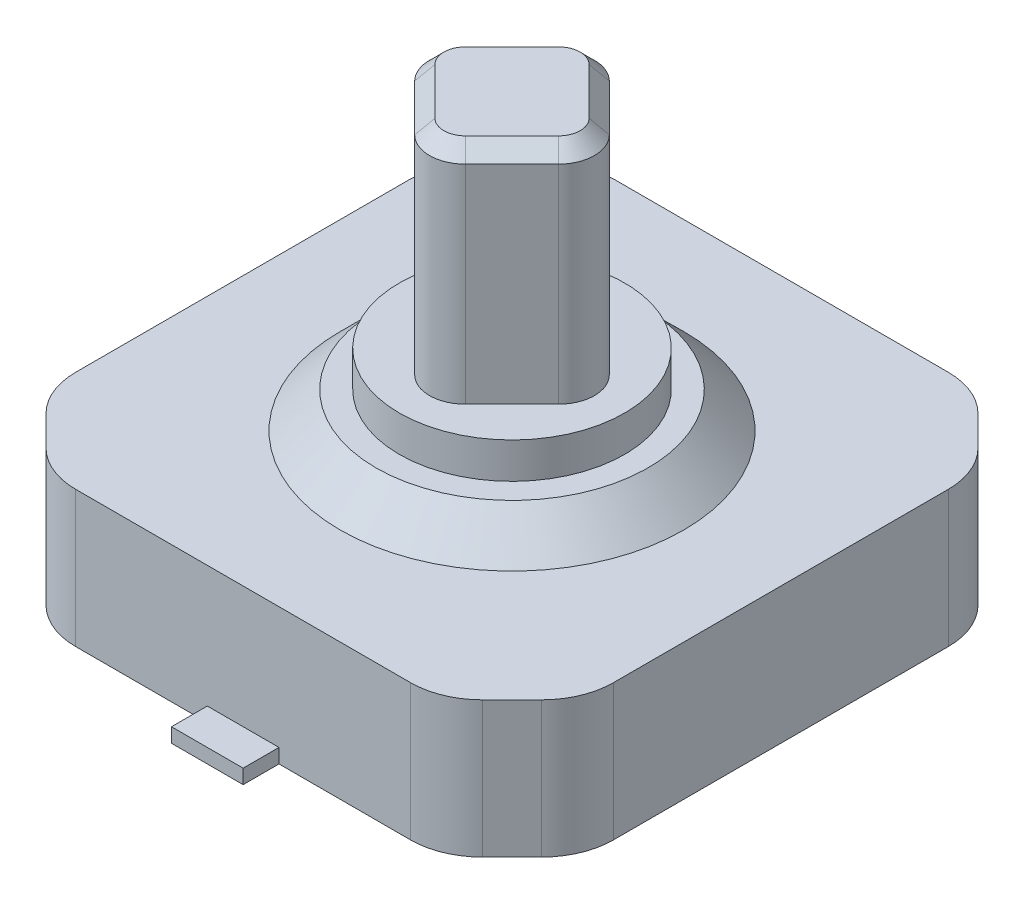
from build123d import *

# Parameters (mm, degrees)
BOSS_EXTRUDE1_DEPTH = 1.9
BOSS_EXTRUDE2_DEPTH = 6
SKETCH3_R           = 2.397073563
BOSS_EXTRUDE3_DEPTH = 0.5
BOSS_EXTRUDE3_TAPER = 45
SKETCH4_R           = 1.57169904
BOSS_EXTRUDE4_DEPTH = 0.5
SKETCH5_W           = 1
SKETCH5_H           = 0.5
BOSS_EXTRUDE5_DEPTH = 0.2
CHAMFER1_SIZE       = 0.2


with BuildPart() as part:
    # Sketch1 → Boss-Extrude1 (new body)
    with BuildSketch(Plane(origin=(0, 0, 0), x_dir=(1, 0, 0), z_dir=(0, 1, 0))):
        with BuildLine():
            Line((-3.457106781, 3.042893219), (-3.042893219, 3.457106781))
            ThreePointArc((-3.042893219, 3.457106781), (-2.71846987, 3.673879533), (-2.335786438, 3.75))
            Line((-2.335786438, 3.75), (2.335786438, 3.75))
            ThreePointArc((2.335786438, 3.75), (2.71846987, 3.673879533), (3.042893219, 3.457106781))
            Line((3.042893219, 3.457106781), (3.457106781, 3.042893219))
            ThreePointArc((3.457106781, 3.042893219), (3.673879533, 2.71846987), (3.75, 2.335786438))
            Line((3.75, 2.335786438), (3.75, -2.335786438))
            ThreePointArc((3.75, -2.335786438), (3.673879533, -2.71846987), (3.457106781, -3.042893219))
            Line((3.457106781, -3.042893219), (3.042893219, -3.457106781))
            ThreePointArc((3.042893219, -3.457106781), (2.71846987, -3.673879533), (2.335786438, -3.75))
            Line((2.335786438, -3.75), (-2.335786438, -3.75))
            ThreePointArc((-2.335786438, -3.75), (-2.71846987, -3.673879533), (-3.042893219, -3.457106781))
            Line((-3.042893219, -3.457106781), (-3.457106781, -3.042893219))
            ThreePointArc((-3.457106781, -3.042893219), (-3.673879533, -2.71846987), (-3.75, -2.335786438))
            Line((-3.75, -2.335786438), (-3.75, 2.335786438))
            ThreePointArc((-3.75, 2.335786438), (-3.673879533, 2.71846987), (-3.457106781, 3.042893219))
        make_face()
    extrude(amount=BOSS_EXTRUDE1_DEPTH)

    # Sketch2 → Boss-Extrude2 (add)
    with BuildSketch(Plane(origin=(0, 0, 0), x_dir=(1, 0, 0), z_dir=(0, 1, 0))):
        with BuildLine():
            Line((0.353553391, -1.004091629), (1.004091629, -0.353553391))
            ThreePointArc((1.004091629, -0.353553391), (1.150538239, 0), (1.004091629, 0.353553391))
            Line((1.004091629, 0.353553391), (0.353553391, 1.004091629))
            ThreePointArc((0.353553391, 1.004091629), (0, 1.150538239), (-0.353553391, 1.004091629))
            Line((-0.353553391, 1.004091629), (-1.004091629, 0.353553391))
            ThreePointArc((-1.004091629, 0.353553391), (-1.150538239, 0), (-1.004091629, -0.353553391))
            Line((-1.004091629, -0.353553391), (-0.353553391, -1.004091629))
            ThreePointArc((-0.353553391, -1.004091629), (0, -1.150538239), (0.353553391, -1.004091629))
        make_face()
    extrude(amount=BOSS_EXTRUDE2_DEPTH)

    # Sketch3 → Boss-Extrude3 (add)
    with BuildSketch(Plane(origin=(0, 1.9, 0), x_dir=(1, 0, 0), z_dir=(0, 1, 0))):
        Circle(SKETCH3_R)
    extrude(amount=BOSS_EXTRUDE3_DEPTH, taper=BOSS_EXTRUDE3_TAPER)

    # Sketch4 → Boss-Extrude4 (add)
    with BuildSketch(Plane(origin=(0, 2.4, 0), x_dir=(1, 0, 0), z_dir=(0, 1, 0))):
        Circle(SKETCH4_R)
    extrude(amount=BOSS_EXTRUDE4_DEPTH)

    # Sketch5 → Boss-Extrude5 (add)
    with BuildSketch(Plane(origin=(0, 0, 0), x_dir=(1, 0, 0), z_dir=(0, 1, 0))):
        with Locations((0, -4)):
            Rectangle(SKETCH5_W, SKETCH5_H)
        with Locations((0, 4)):
            Rectangle(SKETCH5_W, SKETCH5_H)
    extrude(amount=BOSS_EXTRUDE5_DEPTH)

    # Chamfer1
    chamfer1_edges = [part.edges().sort_by_distance(p)[0] for p in [
        (0, 6, 1.150538239),
        (0.67882251, 6, 0.67882251),
        (1.150538239, 6, 0),
        (0.67882251, 6, -0.67882251),
        (0, 6, -1.150538239),
        (-0.67882251, 6, -0.67882251),
        (-1.150538239, 6, 0),
        (-0.67882251, 6, 0.67882251),
    ]]
    chamfer(chamfer1_edges, length=CHAMFER1_SIZE)


solid = part.part
